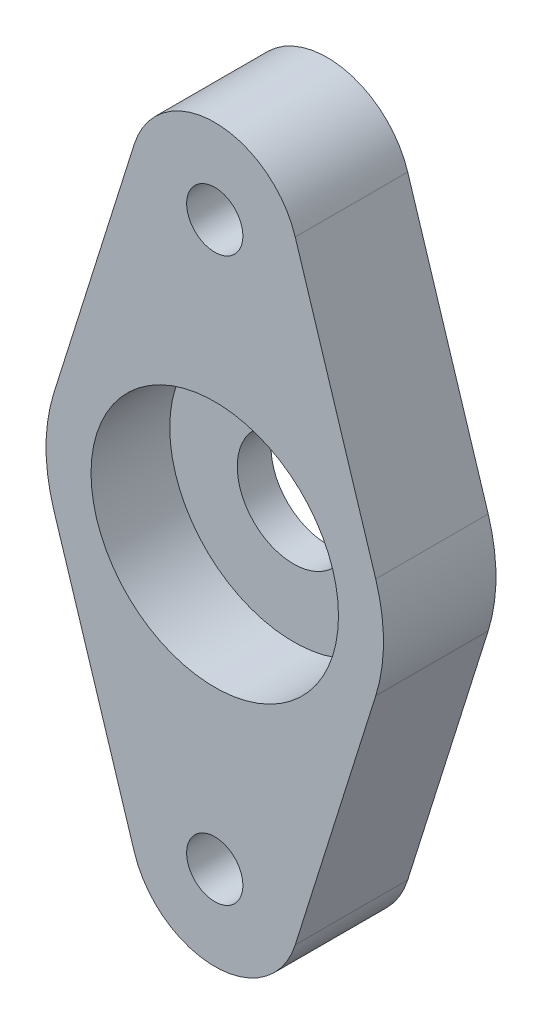
from build123d import *

# Parameters (mm, degrees)
SKETCH_1_R          = 2.5
EXTRUDE_1_DEPTH     = 10
SKETCH_2_R          = 11
CUT_EXTRUDE_1_DEPTH = 7
CUT_EXTRUDE_2_REACH = 5
SKETCH_3_R          = 5


with BuildPart() as part:
    # Эскиз1 → Бобышка-Вытянуть1 (new body)
    with BuildSketch(Plane.XY):
        with BuildLine():
            Line((-14.309088021, 4.5), (-7.154544011, 27.25))
            ThreePointArc((-7.154544011, 27.25), (0, 32.5), (7.154544011, 27.25))
            Line((7.154544011, 27.25), (14.309088021, 4.5))
            ThreePointArc((14.309088021, 4.5), (15, 0), (14.309088021, -4.5))
            Line((14.309088021, -4.5), (7.154544011, -27.25))
            ThreePointArc((7.154544011, -27.25), (0, -32.5), (-7.154544011, -27.25))
            Line((-7.154544011, -27.25), (-14.309088021, -4.5))
            ThreePointArc((-14.309088021, -4.5), (-15, 0), (-14.309088021, 4.5))
        make_face()
        with Locations((0, 25)):
            Circle(SKETCH_1_R, mode=Mode.SUBTRACT)
        with Locations((0, -25)):
            Circle(SKETCH_1_R, mode=Mode.SUBTRACT)
    extrude(amount=EXTRUDE_1_DEPTH)

    # Эскиз2 → Вырез-Вытянуть1 (cut)
    with BuildSketch(Plane.XY.offset(10)):
        Circle(SKETCH_2_R)
    extrude(amount=-CUT_EXTRUDE_1_DEPTH, mode=Mode.SUBTRACT)

    # Эскиз3 → Вырез-Вытянуть2 (cut, up to next)
    with BuildSketch(Plane.XY.offset(3), mode=Mode.PRIVATE) as cut_extrude_2_sk1:
        Circle(SKETCH_3_R)
    cut_extrude_2_tool1 = extrude(cut_extrude_2_sk1.sketch, amount=-CUT_EXTRUDE_2_REACH, mode=Mode.PRIVATE) & part.part
    add(cut_extrude_2_tool1.solids().sort_by_distance((0, 0, 3))[0], mode=Mode.SUBTRACT)


solid = part.part
